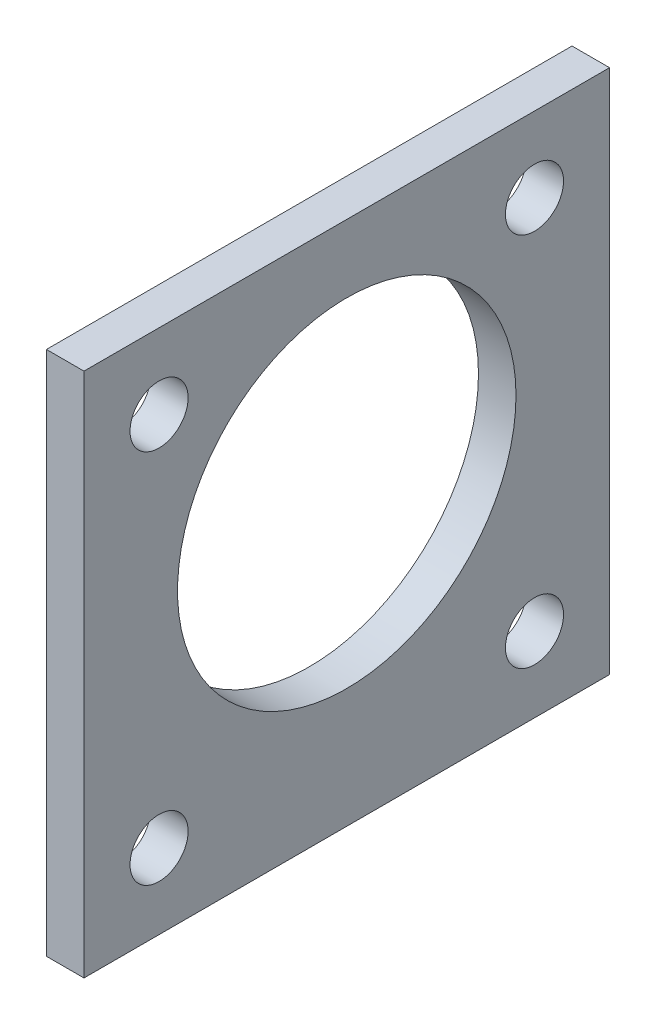
from build123d import *

# Parameters (mm, degrees)
SKETCH1_W           = 44.45
SKETCH1_H           = 44.45
BOSS_EXTRUDE1_DEPTH = 3.175
SKETCH2_R           = 14.3129
SKETCH2_R_2         = 2.45745
CUT_EXTRUDE1_DEPTH  = 4.175


with BuildPart() as part:
    # Sketch1 → Boss-Extrude1 (new body)
    with BuildSketch(Plane(origin=(0, 0, 0), x_dir=(0, 0, -1), z_dir=(1, 0, 0))):
        Rectangle(SKETCH1_W, SKETCH1_H)
    extrude(amount=BOSS_EXTRUDE1_DEPTH)

    # Sketch2 → Cut-Extrude1 (cut, through all)
    with BuildSketch(Plane(origin=(3.175, 0, 0), x_dir=(0, 0, -1), z_dir=(1, 0, 0))):
        with Locations((0, 2.175)):
            Circle(SKETCH2_R)
        with Locations((-15.875, 15.875)):
            Circle(SKETCH2_R_2)
        with Locations((15.875, 15.875)):
            Circle(SKETCH2_R_2)
        with Locations((15.875, -15.875)):
            Circle(SKETCH2_R_2)
        with Locations((-15.875, -15.875)):
            Circle(SKETCH2_R_2)
    extrude(amount=-CUT_EXTRUDE1_DEPTH, mode=Mode.SUBTRACT)


solid = part.part
